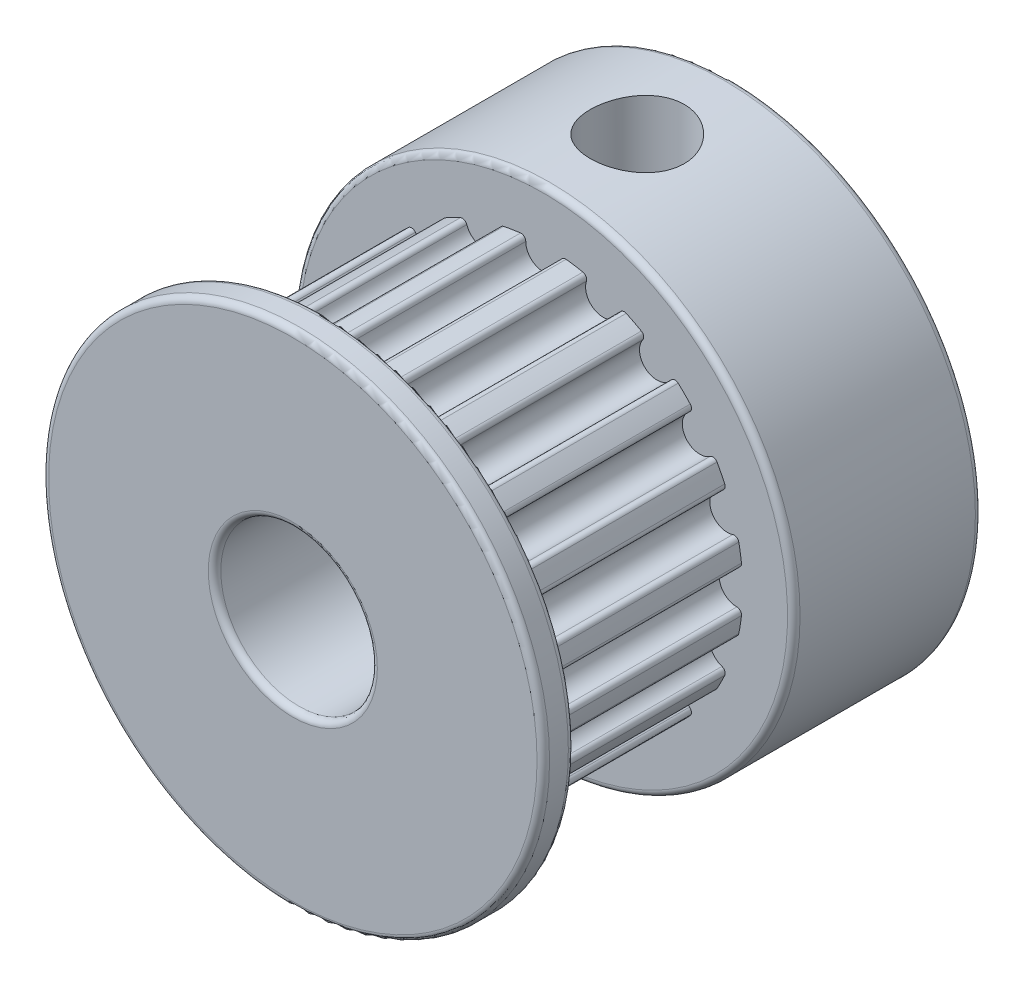
from build123d import *

# Parameters (mm, degrees)
IZIM1_R                        = 6.37
IZIM1_R_2                      = 2.5
Y_KSEKLIK_EKSTR_ZYON1_DEPTH    = 7
KES_EKSTR_ZYON2_DEPTH          = 7
RADYUS2_R                      = 0.15
DAIRESEL_KAPLAMA2_COUNT        = 20
RADYUS2_OF_DAIRESEL_KAPLAMA2_R = 0.15
IZIM4_R                        = 8
IZIM4_R_2                      = 2.5
Y_KSEKLIK_EKSTR_ZYON2_DEPTH    = 1
IZIM5_R                        = 8
IZIM5_R_2                      = 2.5
Y_KSEKLIK_EKSTR_ZYON4_DEPTH    = 6
RADYUS3_R                      = 0.2
IZIM6_R                        = 1.5
KES_EKSTR_ZYON3_DEPTH          = 10


with BuildPart() as part:
    # Çizim1 → Yükseklik-Ekstrüzyon1 (new body)
    with BuildSketch(Plane.XY):
        Circle(IZIM1_R)
        Circle(IZIM1_R_2, mode=Mode.SUBTRACT)
    extrude(amount=Y_KSEKLIK_EKSTR_ZYON1_DEPTH)

    # Çizim2 → Kes-Ekstrüzyon2 (cut)
    with BuildSketch(Plane.XY.offset(7)):
        with BuildLine():
            ThreePointArc((-0.53434772, 6.347548544), (0, 5.62), (0.53434772, 6.347548544))
            ThreePointArc((0.53434772, 6.347548544), (0, 6.37), (-0.53434772, 6.347548544))
        make_face()
    kes_ekstr_zyon2 = extrude(amount=-KES_EKSTR_ZYON2_DEPTH, mode=Mode.SUBTRACT)

    # Radyus2
    radyus2_edges = [part.edges().sort_by_distance(p)[0] for p in [
        (0.53434772, 6.347548544, 3.5),
        (-0.53434772, 6.347548544, 3.5),
    ]]
    fillet(radyus2_edges, radius=RADYUS2_R)

    # Dairesel Kaplama2: Kes-Ekstrüzyon2 ×20 about axis
    dairesel_kaplama2_axis = Axis((0, 0, 0), (0, 0, 1))
    for i in range(1, DAIRESEL_KAPLAMA2_COUNT):
        add(kes_ekstr_zyon2.rotate(dairesel_kaplama2_axis, i * 360 / DAIRESEL_KAPLAMA2_COUNT), mode=Mode.SUBTRACT)

    # Radyus2 of Dairesel Kaplama2
    radyus2_of_dairesel_kaplama2_edges = [part.edges().sort_by_distance(p)[0] for p in [
        (-1.453305492, 6.201999931, 3.5),
        (-2.469695253, 5.871754879, 3.5),
        (-3.298699036, 5.449356354, 3.5),
        (-4.163291808, 4.821192935, 3.5),
        (-4.821192935, 4.163291808, 3.5),
        (-5.449356354, 3.298699036, 3.5),
        (-5.871754879, 2.469695253, 3.5),
        (-6.201999931, 1.453305492, 3.5),
        (-6.347548544, 0.53434772, 3.5),
        (-6.347548544, -0.53434772, 3.5),
        (-6.201999931, -1.453305492, 3.5),
        (-5.871754879, -2.469695253, 3.5),
        (-5.449356354, -3.298699036, 3.5),
        (-4.821192935, -4.163291808, 3.5),
        (-4.163291808, -4.821192935, 3.5),
        (-3.298699036, -5.449356354, 3.5),
        (-2.469695253, -5.871754879, 3.5),
        (-1.453305492, -6.201999931, 3.5),
        (-0.53434772, -6.347548544, 3.5),
        (0.53434772, -6.347548544, 3.5),
        (1.453305492, -6.201999931, 3.5),
        (2.469695253, -5.871754879, 3.5),
        (3.298699036, -5.449356354, 3.5),
        (4.163291808, -4.821192935, 3.5),
        (4.821192935, -4.163291808, 3.5),
        (5.449356354, -3.298699036, 3.5),
        (5.871754879, -2.469695253, 3.5),
        (6.201999931, -1.453305492, 3.5),
        (6.347548544, -0.53434772, 3.5),
        (6.347548544, 0.53434772, 3.5),
        (6.201999931, 1.453305492, 3.5),
        (5.871754879, 2.469695253, 3.5),
        (5.449356354, 3.298699036, 3.5),
        (4.821192935, 4.163291808, 3.5),
        (4.163291808, 4.821192935, 3.5),
        (3.298699036, 5.449356354, 3.5),
        (2.469695253, 5.871754879, 3.5),
        (1.453305492, 6.201999931, 3.5),
    ]]
    fillet(radyus2_of_dairesel_kaplama2_edges, radius=RADYUS2_OF_DAIRESEL_KAPLAMA2_R)

    # Çizim4 → Yükseklik-Ekstrüzyon2 (add)
    with BuildSketch(Plane.XY.offset(7)):
        Circle(IZIM4_R)
        Circle(IZIM4_R_2, mode=Mode.SUBTRACT)
    extrude(amount=Y_KSEKLIK_EKSTR_ZYON2_DEPTH)

    # Çizim5 → Yükseklik-Ekstrüzyon4 (add)
    with BuildSketch(Plane(origin=(0, 0, 0), x_dir=(-1, 0, 0), z_dir=(0, 0, -1))):
        with Locations(Location((0, 0, 0), (0, 0, 180))):  # turned: the seam where the file's is
            Circle(IZIM5_R)
        Circle(IZIM5_R_2, mode=Mode.SUBTRACT)
    extrude(amount=Y_KSEKLIK_EKSTR_ZYON4_DEPTH)

    # Radyus3
    radyus3_edges = [part.edges().sort_by_distance(p)[0] for p in [
        (-8, 0, 8),
        (-8, 0, 7),
        (-2.5, 0, 8),
        (-8, 0, -6),
        (-8, 0, 0),
        (2.5, 0, -6),
    ]]
    fillet(radyus3_edges, radius=RADYUS3_R)

    # Çizim6 → Kes-Ekstrüzyon3 (cut)
    with BuildSketch(Plane(origin=(0, 10, 0), x_dir=(1, 0, 0), z_dir=(0, 1, 0))):
        with Locations(Location((0, 3, 0), (0, 0, 270))):  # turned: the seam where the file's is
            Circle(IZIM6_R)
    extrude(amount=-KES_EKSTR_ZYON3_DEPTH, mode=Mode.SUBTRACT)


solid = part.part
